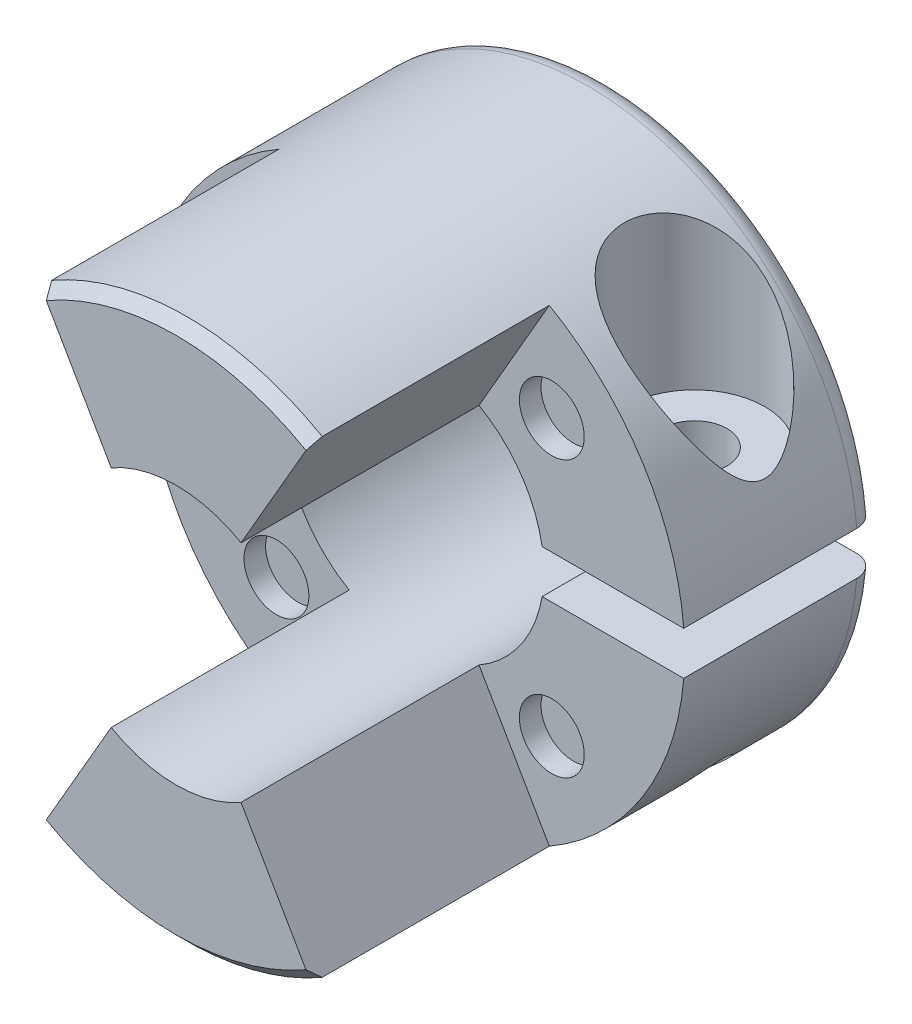
from build123d import *

# Parameters (mm, degrees)
ESBO_O1_R                 = 12.5
RESSALTO_EXTRUS_O1_DEPTH  = 20
CORTE_EXTRUS_O3_DEPTH     = 11
ESBO_O3_R                 = 6
CORTE_EXTRUS_O4_DEPTH     = 21
ESBO_O6_W                 = 12
ESBO_O6_H                 = 2
CORTE_EXTRUS_O5_DEPTH     = 10
CORTE_EXTRUS_O6_START     = -3
ESBO_O7_R                 = 3.25
CORTE_EXTRUS_O6_DEPTH     = 9.5
FURO_ROSCADO_DE_M3X0_51_D = 2.5
FILETE1_R                 = 1
ESBO_O10_R                = 1.5
CORTE_EXTRUS_O7_DEPTH     = 1
CHANFRO1_SIZE             = 0.5
CORTE_EXTRUS_O8_REACH     = 18.5
ESBO_O11_R                = 1.5
PADR_OCIRCULAR1_COUNT     = 4
CHANFRO2_SIZE             = 0.5


with BuildPart() as part:
    # Esboço1 → Ressalto-extrusão1 (new body)
    with BuildSketch(Plane.XY):
        Circle(ESBO_O1_R)
    extrude(amount=RESSALTO_EXTRUS_O1_DEPTH)

    # Esboço2 → Corte-extrusão3 (cut)
    with BuildSketch(Plane.XY.offset(20)):
        with BuildLine():
            Line((0, 0), (6.25, 10.825317547))
            ThreePointArc((6.25, 10.825317547), (12.5, 0), (6.25, -10.825317547))
            Line((6.25, -10.825317547), (0, 0))
        make_face()
    corte_extrus_o3 = extrude(amount=-CORTE_EXTRUS_O3_DEPTH, mode=Mode.SUBTRACT)

    # Esboço3 → Corte-extrusão4 (cut, through all)
    with BuildSketch(Plane(origin=(0, 0, 0), x_dir=(-1, 0, 0), z_dir=(0, 0, -1))):
        Circle(ESBO_O3_R)
    extrude(amount=-CORTE_EXTRUS_O4_DEPTH, mode=Mode.SUBTRACT)

    # Espelhar1: Corte-extrusão3 across plane
    add(corte_extrus_o3.mirror(Plane(origin=(0, 0, 0), x_dir=(0, 0, 1), z_dir=(1, 0, 0))), mode=Mode.SUBTRACT)

    # Esboço6 → Corte-extrusão5 (cut, through all)
    with BuildSketch(Plane.XY.offset(9)):
        with Locations((7, 0)):
            Rectangle(ESBO_O6_W, ESBO_O6_H)
    extrude(amount=-CORTE_EXTRUS_O5_DEPTH, mode=Mode.SUBTRACT)

    # Esboço7 → Corte-extrusão6 (cut, through all)
    with BuildSketch(Plane.XZ.offset(-1).offset(CORTE_EXTRUS_O6_START)):
        with Locations((8.459935794, 4.5)):
            Circle(ESBO_O7_R)
    extrude(amount=-CORTE_EXTRUS_O6_DEPTH, mode=Mode.SUBTRACT)

    # Furo roscado de M3x0.51 (through all)
    with Locations(Plane(origin=(0, 4, 0), x_dir=(1, 0, 0), z_dir=(0, 1, 0))):
        with Locations((8.459935794, -4.5)):
            Hole(FURO_ROSCADO_DE_M3X0_51_D / 2)

    # Filete1
    filete1_edges = [part.edges().sort_by_distance(p)[0] for p in [
        (-12.5, 0, 0),
    ]]
    fillet(filete1_edges, radius=FILETE1_R)

    # Esboço10 → Corte-extrusão7 (cut)
    with BuildSketch(Plane.XY.offset(9)):
        with Locations((6.363961031, -6.363961031)):
            Circle(ESBO_O10_R)
    corte_extrus_o7 = extrude(amount=-CORTE_EXTRUS_O7_DEPTH, mode=Mode.SUBTRACT)

    # Chanfro1
    chanfro1_edges = [part.edges().sort_by_distance(p)[0] for p in [
        (0, -12.5, 20),
        (0, 12.5, 20),
    ]]
    chamfer(chanfro1_edges, length=CHANFRO1_SIZE)

    # Esboço11 → Corte-extrusão8 (cut, up to next)
    with BuildSketch(Plane(origin=(0, 4, 0), x_dir=(1, 0, 0), z_dir=(0, 1, 0)), mode=Mode.PRIVATE) as corte_extrus_o8_sk1:
        with Locations((8.459935794, -4.5)):
            Circle(ESBO_O11_R)
    corte_extrus_o8_tool1 = extrude(corte_extrus_o8_sk1.sketch, amount=-CORTE_EXTRUS_O8_REACH, mode=Mode.PRIVATE) & part.part
    add(corte_extrus_o8_tool1.solids().sort_by_distance((8.459936, 4, 4.5))[0], mode=Mode.SUBTRACT)

    # PadrãoCircular1: Corte-extrusão7 ×4 about axis
    padr_ocircular1_axis = Axis((0, 0, 0), (0, 0, 1))
    for i in range(1, PADR_OCIRCULAR1_COUNT):
        add(corte_extrus_o7.rotate(padr_ocircular1_axis, i * 360 / PADR_OCIRCULAR1_COUNT), mode=Mode.SUBTRACT)

    # Chanfro2
    chanfro2_edges = [part.edges().sort_by_distance(p)[0] for p in [
        (-6, 0, 0),
    ]]
    chamfer(chanfro2_edges, length=CHANFRO2_SIZE)


solid = part.part
